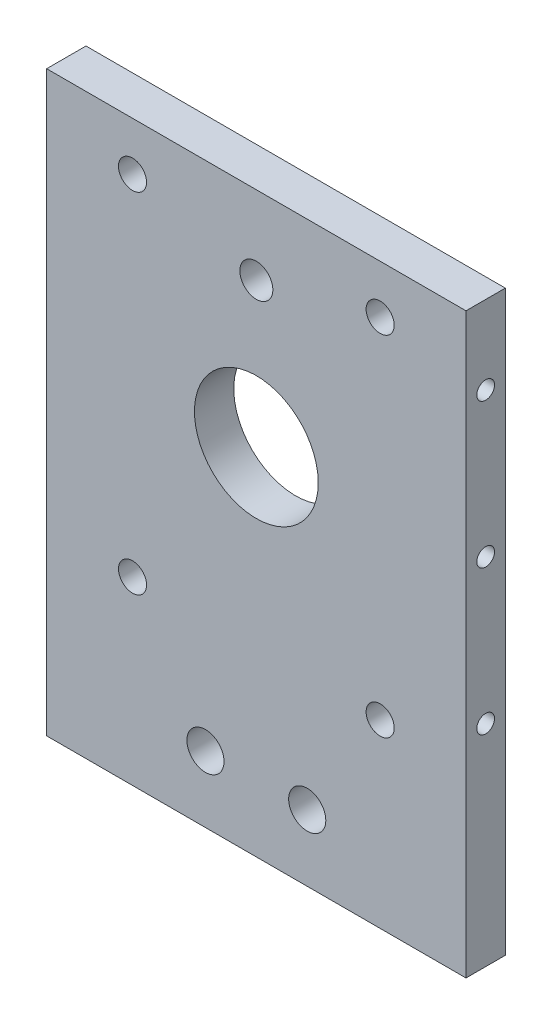
from build123d import *

# Parameters (mm, degrees)
CROQUIS1_W              = 101.6
CROQUIS1_H              = 108
SALIENTE_EXTRUIR1_DEPTH = 9.525
CROQUIS2_R              = 15
CROQUIS2_R_2            = 3.4
CORTAR_EXTRUIR1_DEPTH   = 10.525
CROQUIS3_R              = 2.15
CORTAR_EXTRUIR2_DEPTH   = 15
CROQUIS4_R              = 2.15
CORTAR_EXTRUIR3_DEPTH   = 15
CROQUIS5_W              = 101.6
CROQUIS5_H              = 32
SALIENTE_EXTRUIR2_DEPTH = 9.525
CROQUIS6_R              = 4.5
CROQUIS6_R_2            = 4
CORTAR_EXTRUIR4_DEPTH   = 101.6


with BuildPart() as part:
    # Croquis1 → Saliente-Extruir1 (new body)
    with BuildSketch(Plane.XY):
        Rectangle(CROQUIS1_W, CROQUIS1_H)
    extrude(amount=SALIENTE_EXTRUIR1_DEPTH)

    # Croquis2 → Cortar-Extruir1 (cut, through all)
    with BuildSketch(Plane.XY.offset(9.525)):
        Circle(CROQUIS2_R)
        with Locations((30, -42.25)):
            Circle(CROQUIS2_R_2)
        with Locations((-30, -42.25)):
            Circle(CROQUIS2_R_2)
        with Locations((30, 42.25)):
            Circle(CROQUIS2_R_2)
        with Locations((-30, 42.25)):
            Circle(CROQUIS2_R_2)
    extrude(amount=-CORTAR_EXTRUIR1_DEPTH, mode=Mode.SUBTRACT)

    # Croquis3 → Cortar-Extruir2 (cut)
    with BuildSketch(Plane.ZY.offset(50.8)):
        with Locations((4.7625, 0)):
            Circle(CROQUIS3_R)
        with Locations((4.7625, -35)):
            Circle(CROQUIS3_R)
        with Locations((4.7625, 35)):
            Circle(CROQUIS3_R)
    extrude(amount=-CORTAR_EXTRUIR2_DEPTH, mode=Mode.SUBTRACT)

    # Croquis4 → Cortar-Extruir3 (cut)
    with BuildSketch(Plane(origin=(50.8, 0, 0), x_dir=(0, 0, -1), z_dir=(1, 0, 0))):
        with Locations((-4.7625, 0)):
            Circle(CROQUIS4_R)
        with Locations((-4.7625, -35)):
            Circle(CROQUIS4_R)
        with Locations((-4.7625, 35)):
            Circle(CROQUIS4_R)
    extrude(amount=-CORTAR_EXTRUIR3_DEPTH, mode=Mode.SUBTRACT)

    # Croquis5 → Saliente-Extruir2 (add)
    with BuildSketch(Plane.XY.offset(9.525)):
        with Locations((0, -70)):
            Rectangle(CROQUIS5_W, CROQUIS5_H)
    extrude(amount=-SALIENTE_EXTRUIR2_DEPTH)

    # Croquis6 → Cortar-Extruir4 (cut)
    with BuildSketch(Plane.XY.offset(9.525)):
        with Locations((12.329020614, -69.921350464)):
            Circle(CROQUIS6_R)
        with Locations((-12.329020614, -69.921350464)):
            Circle(CROQUIS6_R)
        with Locations((0, 35.004884714)):
            Circle(CROQUIS6_R_2)
    extrude(amount=-CORTAR_EXTRUIR4_DEPTH, mode=Mode.SUBTRACT)


solid = part.part
